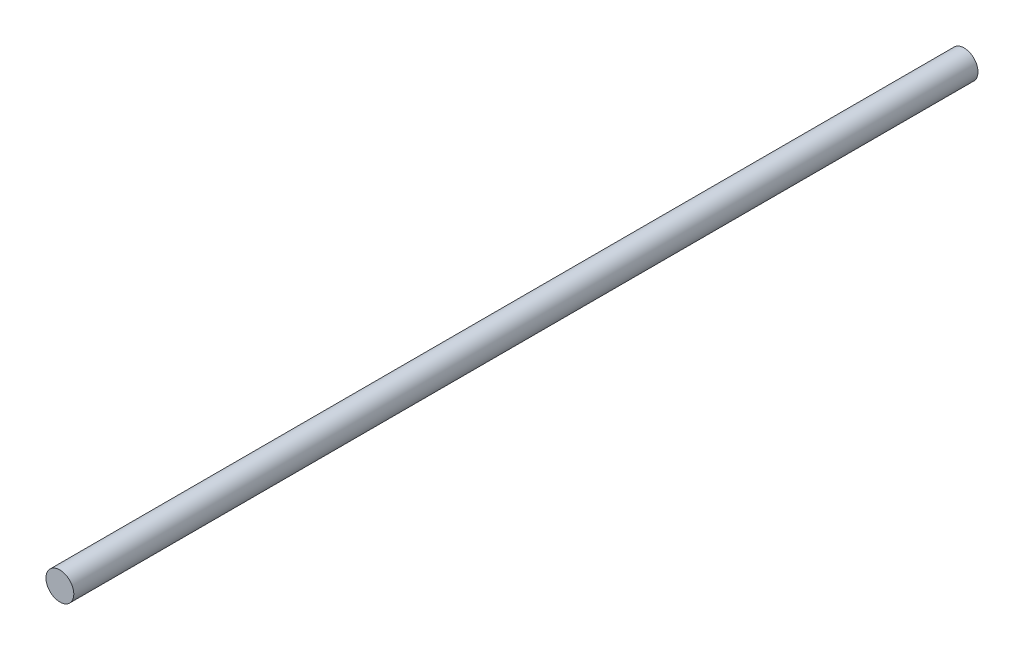
from build123d import *

# Parameters (mm, degrees)
SKETCH1_R           = 2
BOSS_EXTRUDE1_DEPTH = 130


with BuildPart() as part:
    # Sketch1 → Boss-Extrude1 (new body)
    with BuildSketch(Plane.XY):
        Circle(SKETCH1_R)
    extrude(amount=BOSS_EXTRUDE1_DEPTH)


solid = part.part
